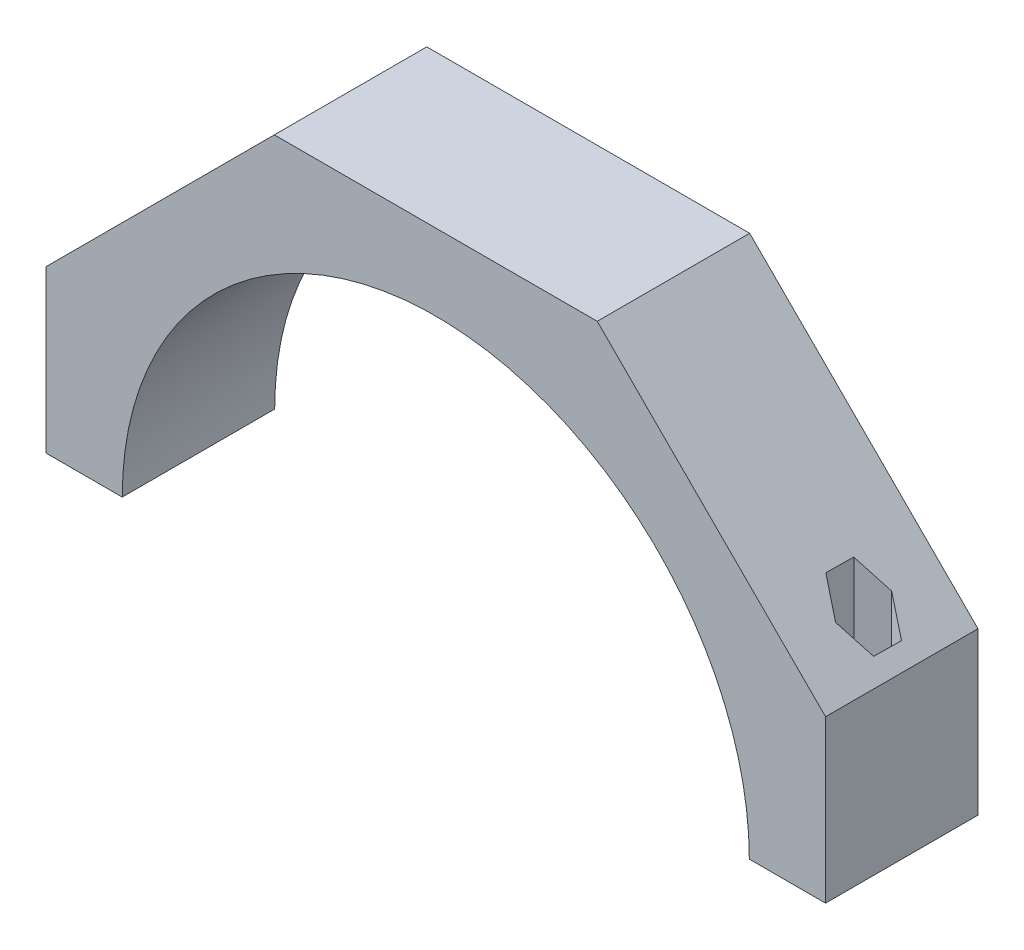
from build123d import *

# Parameters (mm, degrees)
BOSS_EXTRUDE1_DEPTH = 19.05
SKETCH2_R           = 3.429
CUT_EXTRUDE2_DEPTH  = 98.409
SKETCH4_R           = 5.677154031
CUT_EXTRUDE3_DEPTH  = 79.359


with BuildPart() as part:
    # Sketch1 → Boss-Extrude1 (new body, symmetric)
    with BuildSketch(Plane.XY):
        with BuildLine():
            Line((-78.359, 0), (-97.409, 0))
            Line((-97.409, 0), (-97.409, 40.348128897))
            Line((-97.409, 40.348128897), (-40.348128897, 97.409))
            Line((-40.348128897, 97.409), (40.348128897, 97.409))
            Line((40.348128897, 97.409), (97.409, 40.348128897))
            Line((97.409, 40.348128897), (97.409, 0))
            Line((97.409, 0), (78.359, 0))
            ThreePointArc((78.359, 0), (0, 78.359), (-78.359, 0))
        make_face()
    extrude(amount=BOSS_EXTRUDE1_DEPTH, both=True)

    # Sketch2 → Cut-Extrude2 (cut, through all)
    with BuildSketch(Plane.XZ):
        with Locations((87.884, 0)):
            Circle(SKETCH2_R)
        with Locations((-87.884, 0)):
            Circle(SKETCH2_R)
    extrude(amount=-CUT_EXTRUDE2_DEPTH, mode=Mode.SUBTRACT)

    # Sketch4 → Cut-Extrude3 (cut, through all)
    with BuildSketch(Plane(origin=(0, 19.05, 0), x_dir=(-1, 0, 0), z_dir=(0, -1, 0))):
        with Locations((87.884, 0)):
            Circle(SKETCH4_R)
        Polygon((-93.925417492, 3.429), (-93.874309855, -3.517521023), (-87.832892364, -6.946521023), (-81.842582508, -3.429), (-81.893690145, 3.517521023), (-87.935107636, 6.946521023), align=None)
    extrude(amount=-CUT_EXTRUDE3_DEPTH, mode=Mode.SUBTRACT)


solid = part.part
